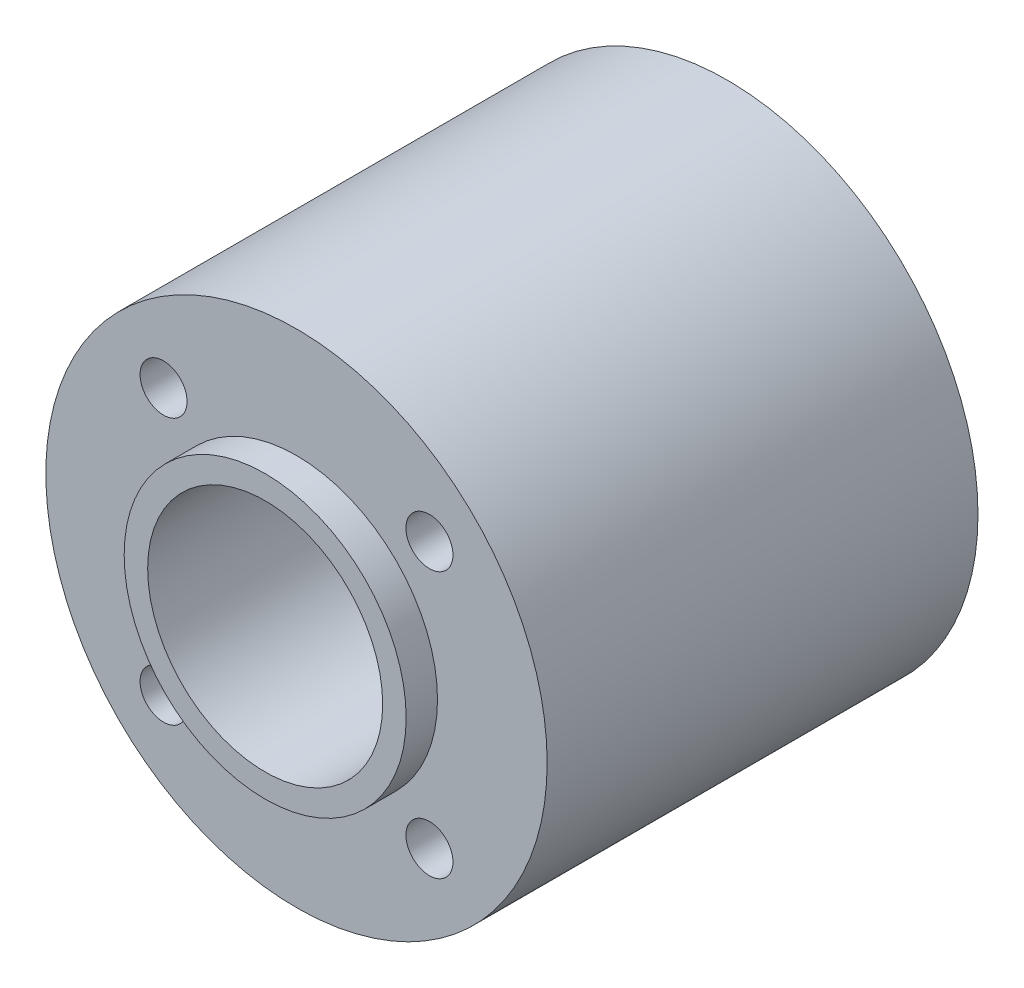
from build123d import *

# Parameters (mm, degrees)
SKETCH1_R                = 16
SKETCH1_R_2              = 7.5
SKETCH1_R_3              = 1.5
BOSS_EXTRUDE1_DEPTH      = 27.5
SKETCH2_R                = 9
SKETCH2_R_2              = 7.5
BOSS_EXTRUDE2_DEPTH      = 2
BOSS_EXTRUDE2_DEPTH_BACK = 29.5
SCALE1_SCALE             = 2


with BuildPart() as part:
    # Sketch1 → Boss-Extrude1 (new body)
    with BuildSketch(Plane.XY):
        Circle(SKETCH1_R)
        Circle(SKETCH1_R_2, mode=Mode.SUBTRACT)
        with Locations((-8.485281374, 8.485281374)):
            Circle(SKETCH1_R_3, mode=Mode.SUBTRACT)
        with Locations((8.485281374, 8.485281374)):
            Circle(SKETCH1_R_3, mode=Mode.SUBTRACT)
        with Locations((8.485281374, -8.485281374)):
            Circle(SKETCH1_R_3, mode=Mode.SUBTRACT)
        with Locations((-8.485281374, -8.485281374)):
            Circle(SKETCH1_R_3, mode=Mode.SUBTRACT)
    extrude(amount=BOSS_EXTRUDE1_DEPTH)

    # Sketch2 → Boss-Extrude2 (add, two sides)
    with BuildSketch(Plane.XY.offset(27.5)) as boss_extrude2_sk:
        Circle(SKETCH2_R)
        Circle(SKETCH2_R_2, mode=Mode.SUBTRACT)
    extrude(amount=BOSS_EXTRUDE2_DEPTH)
    extrude(boss_extrude2_sk.sketch, amount=-BOSS_EXTRUDE2_DEPTH_BACK)


with BuildPart() as part_1:
    # Scale1: scaled about (0, 0, 13.75)
    add(part.part.scale(SCALE1_SCALE).moved(Location((0, 0, -13.75))))


solid = part_1.part
